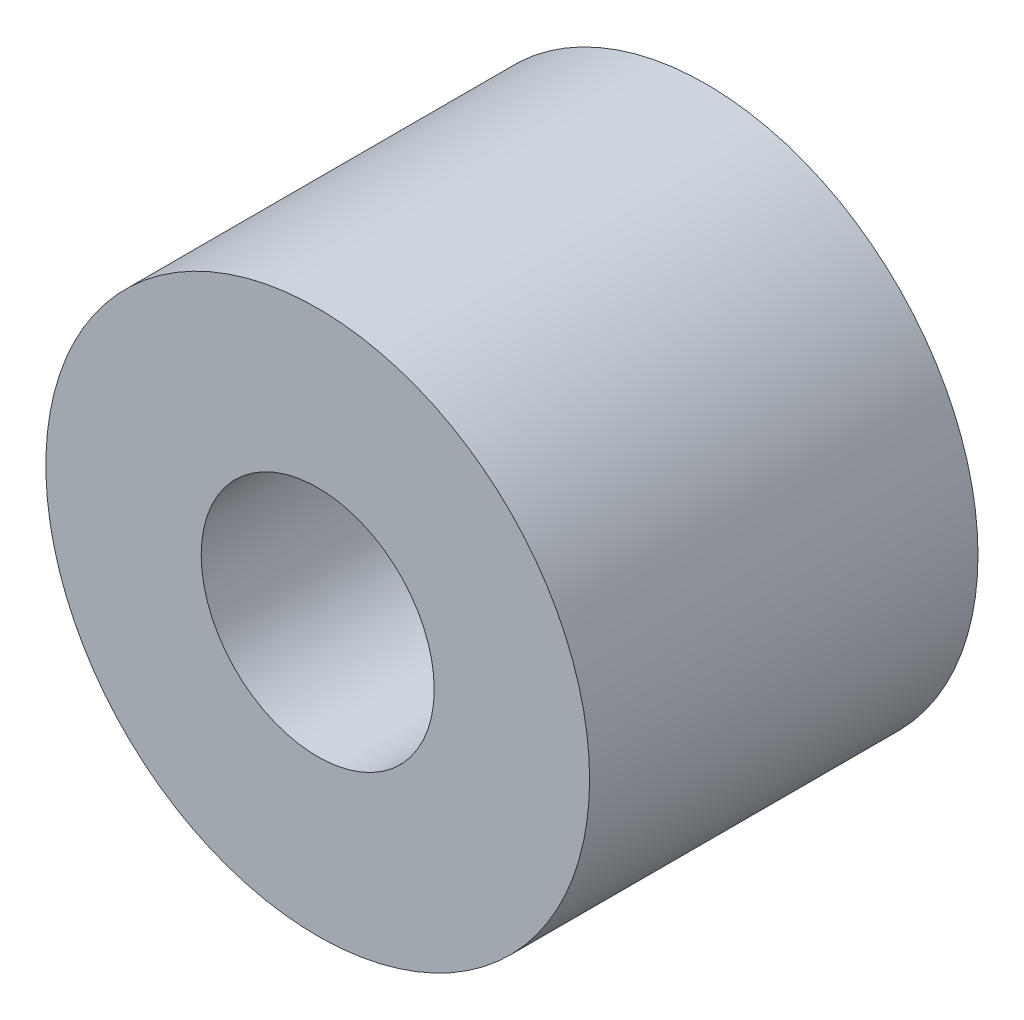
from build123d import *

# Parameters (mm, degrees)
ESQUISSE1_R        = 3.500000067
ESQUISSE1_R_2      = 1.500000067
BOSS_EXTRU_1_DEPTH = 5


with BuildPart() as part:
    # Esquisse1 → Boss.-Extru.1 (new body)
    with BuildSketch(Plane.XY):
        with Locations((-433.068859933, 57.306809003)):
            Circle(ESQUISSE1_R)
        with Locations((-433.068859933, 57.306809003)):
            Circle(ESQUISSE1_R_2, mode=Mode.SUBTRACT)
    extrude(amount=BOSS_EXTRU_1_DEPTH)


solid = part.part
